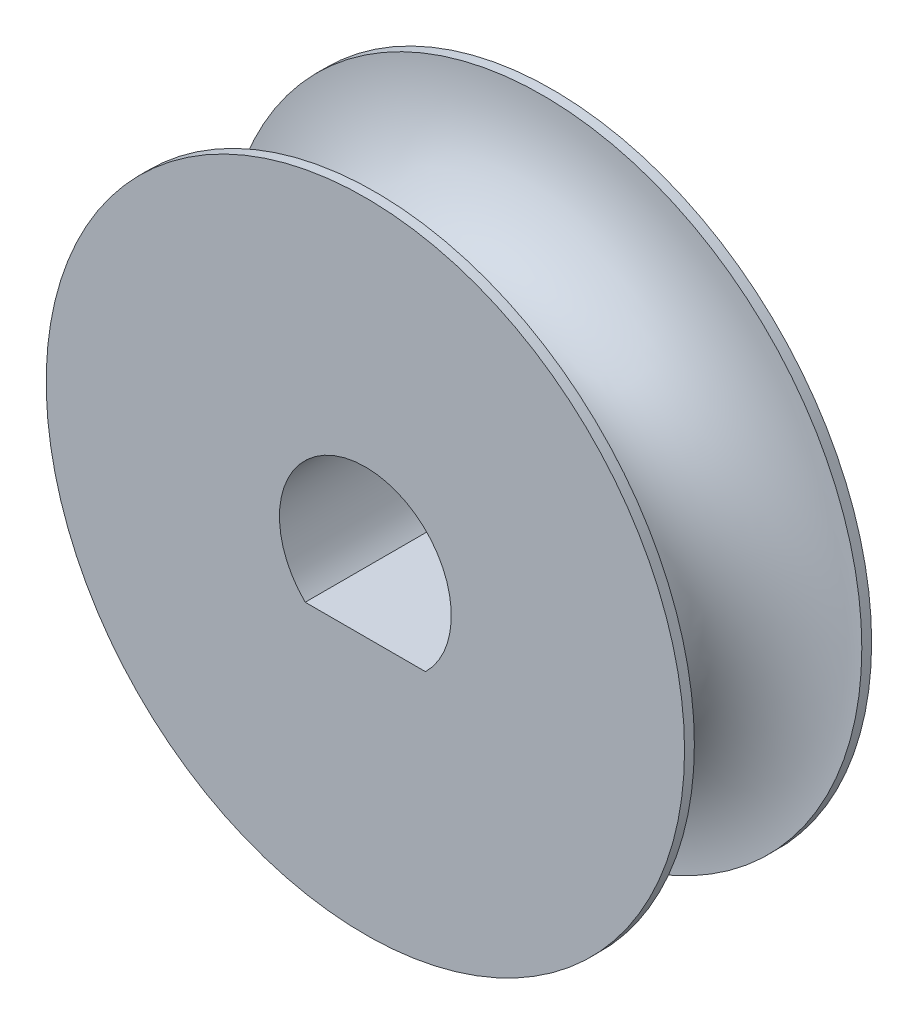
from build123d import *

# Parameters (mm, degrees)
BOSS_EXTRUDE1_START = -2
SKETCH1_R           = 6.5
BOSS_EXTRUDE1_DEPTH = 3.81
SKETCH2_RX          = 2.5
SKETCH2_RY          = 1.705


with BuildPart() as part:
    # Sketch1 → Boss-Extrude1 (new body)
    with BuildSketch(Plane.XY.offset(BOSS_EXTRUDE1_START)):
        with Locations((-25.275773863, 2.907479065)):
            Circle(SKETCH1_R)
        with BuildLine():
            ThreePointArc((-26.500518734, 1.657479065), (-25.275773863, 4.657479065), (-24.051028992, 1.657479065))
            Line((-24.051028992, 1.657479065), (-26.500518734, 1.657479065))
        make_face(mode=Mode.SUBTRACT)
    extrude(amount=-BOSS_EXTRUDE1_DEPTH)

    # Sketch2 → Cut-Revolve1 (revolve, cut)
    with BuildSketch(Plane(origin=(-0.41524981, -2.209102148, 0), x_dir=(-0.9794707520439397, 0.2015863236692392, 0), z_dir=(0.2015863236692392, 0.9794707520439397, 0))):
        with Locations(Location((18.881588986, -3.905), (0, 0, 180))):
            Ellipse(SKETCH2_RX, SKETCH2_RY)
    revolve(axis=Axis((-25.275773863, 2.907479065, 0.773144213), (0, 0, -1)), mode=Mode.SUBTRACT)


solid = part.part
